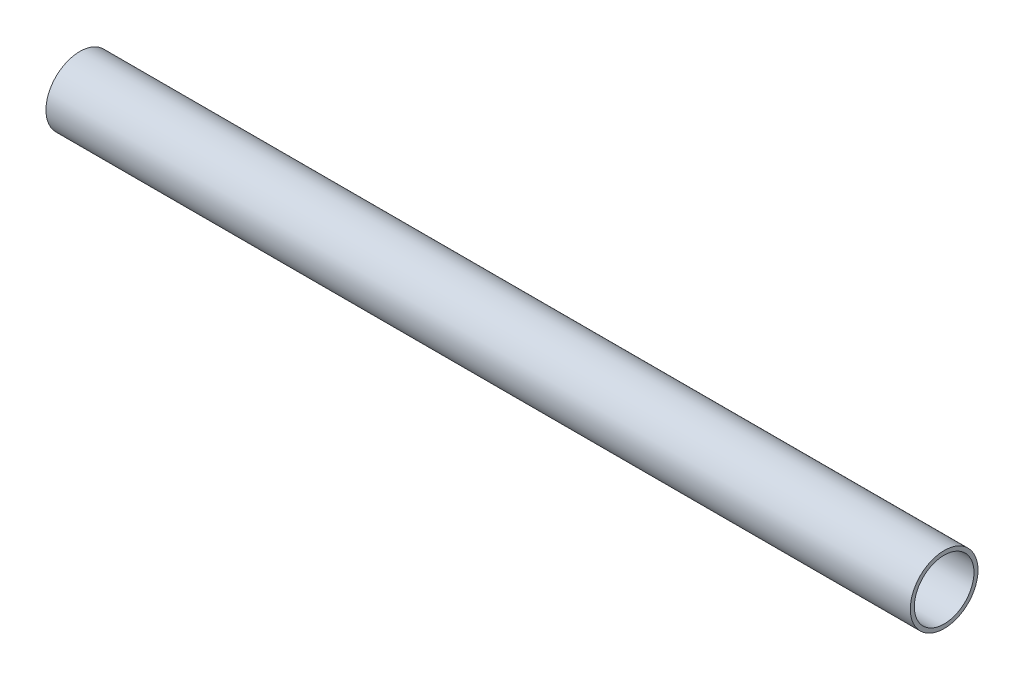
from build123d import *

# Parameters (mm, degrees)
SKETCH1_R           = 41.9
SKETCH1_R_2         = 36.9
BOSS_EXTRUDE1_DEPTH = 1070


with BuildPart() as part:
    # Sketch1 → Boss-Extrude1 (new body)
    with BuildSketch(Plane(origin=(0, 0, 0), x_dir=(0, 0, -1), z_dir=(1, 0, 0))):
        Circle(SKETCH1_R)
        Circle(SKETCH1_R_2, mode=Mode.SUBTRACT)
    extrude(amount=BOSS_EXTRUDE1_DEPTH)


solid = part.part
